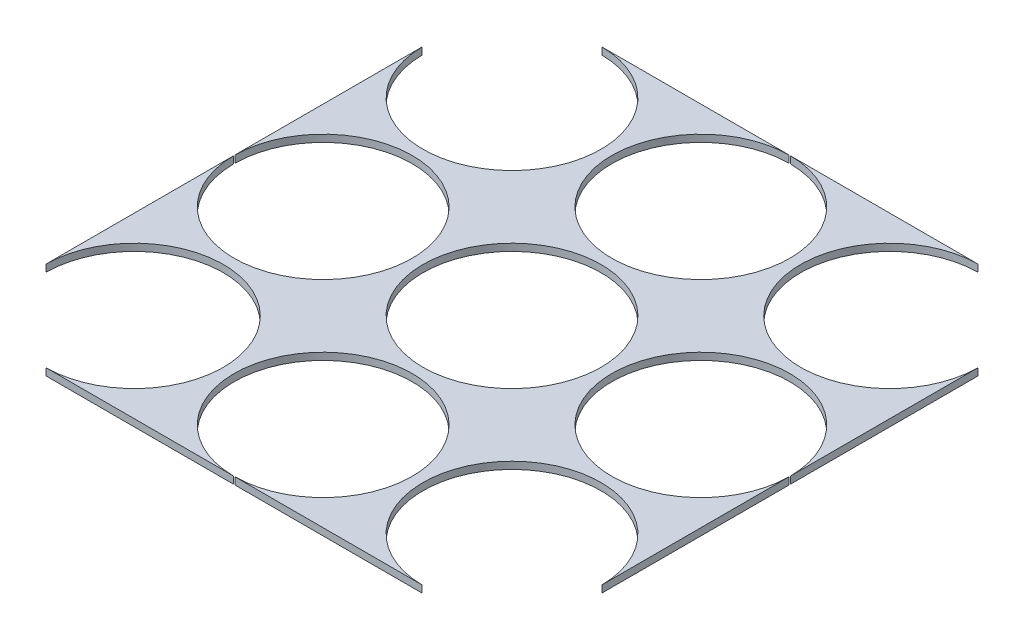
from build123d import *

# Parameters (mm, degrees)
SKETCH3_W           = 247.65
SKETCH3_H           = 247.65
BOSS_EXTRUDE5_DEPTH = 3.175
SKETCH1_R           = 39.6875
CUT_EXTRUDE3_DEPTH  = 4.175


with BuildPart() as part:
    # Sketch3 → Boss-Extrude5 (new body)
    with BuildSketch(Plane(origin=(0, 0, 0), x_dir=(1, 0, 0), z_dir=(0, 1, 0))):
        Rectangle(SKETCH3_W, SKETCH3_H)
    extrude(amount=BOSS_EXTRUDE5_DEPTH)

    # Sketch1 → Cut-Extrude3 (cut, through all)
    with BuildSketch(Plane(origin=(0, 0, 0), x_dir=(1, 0, 0), z_dir=(0, 1, 0))):
        with BuildLine():
            Line((-123.82627, -84.13877), (-123.82627, -123.82627))
            Line((-123.82627, -123.82627), (-84.13877, -123.82627))
            ThreePointArc((-84.13877, -123.82627), (-56.075469622, -56.075469622), (-123.82627, -84.13877))
        make_face()
        with Locations((0, -84.13877)):
            Circle(SKETCH1_R)
        with Locations((84.13877, 0)):
            Circle(SKETCH1_R)
        with Locations((0, 84.13877)):
            Circle(SKETCH1_R)
        with Locations((-84.13877, 0)):
            Circle(SKETCH1_R)
        with BuildLine():
            Line((123.82627, -123.82627), (123.82627, -84.13877))
            ThreePointArc((123.82627, -84.13877), (56.075469622, -56.075469622), (84.13877, -123.82627))
            Line((84.13877, -123.82627), (123.82627, -123.82627))
        make_face()
        with BuildLine():
            Line((-123.82627, 123.82627), (-123.82627, 84.13877))
            ThreePointArc((-123.82627, 84.13877), (-56.075469622, 56.075469622), (-84.13877, 123.82627))
            Line((-84.13877, 123.82627), (-123.82627, 123.82627))
        make_face()
        with BuildLine():
            Line((123.82627, 123.82627), (84.13877, 123.82627))
            ThreePointArc((84.13877, 123.82627), (56.075469622, 56.075469622), (123.82627, 84.13877))
            Line((123.82627, 84.13877), (123.82627, 123.82627))
        make_face()
        Circle(SKETCH1_R)
    extrude(amount=CUT_EXTRUDE3_DEPTH, mode=Mode.SUBTRACT)


solid = part.part
